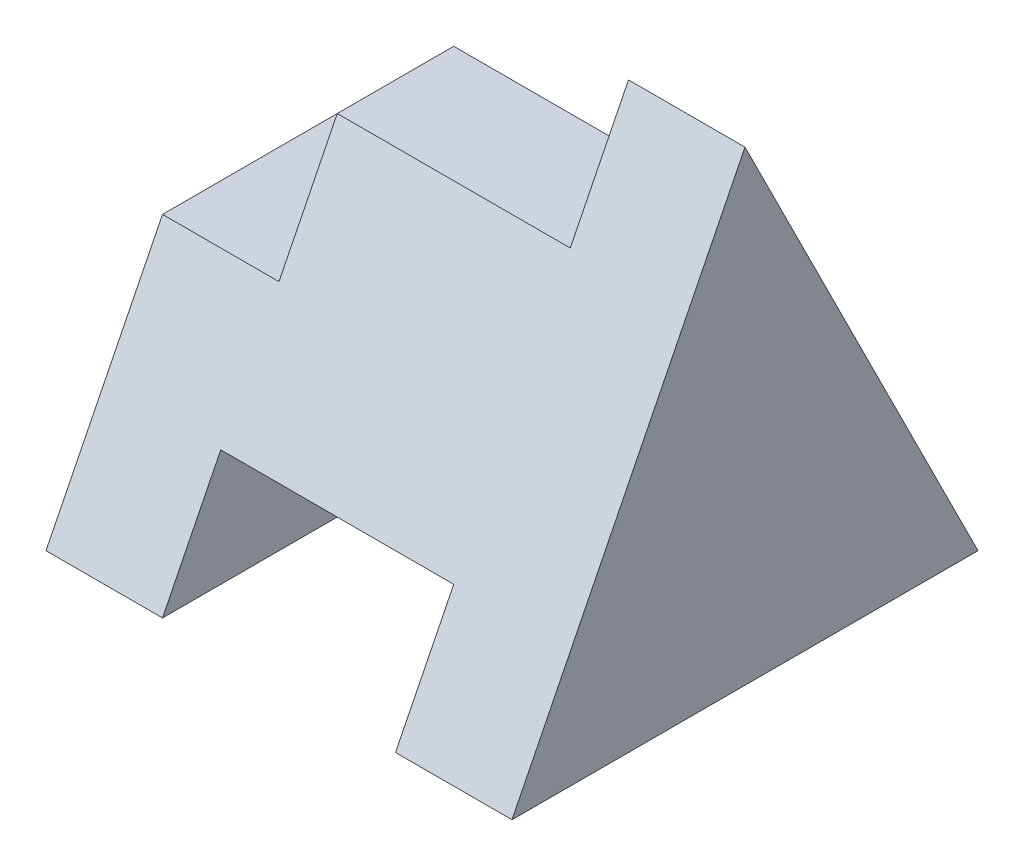
from build123d import *

# Parameters (mm, degrees)
BOSS_EXTRUDE1_DEPTH = 4
CUT_EXTRUDE2_DEPTH  = 10


with BuildPart() as part:
    # Sketch1 → Boss-Extrude1 (new body)
    with BuildSketch(Plane.XY):
        Polygon((0, 0), (0, 2), (1, 2), (1, 3), (3, 3), (3, 4), (4, 4), (4, 0), (3, 0), (3, 1), (1, 1), (1, 0), align=None)
    extrude(amount=BOSS_EXTRUDE1_DEPTH)

    # Sketch3 → Cut-Extrude2 (cut)
    with BuildSketch(Plane.ZY):
        Polygon((1, 2), (2, 4), (0, 4), (0, 2), align=None)
        Polygon((0, 0), (1, 2), (0, 2), align=None)
        Polygon((2, 4), (3, 2), (4, 2), (4, 4), align=None)
        Polygon((3, 2), (4, 0), (4, 2), align=None)
    extrude(amount=-CUT_EXTRUDE2_DEPTH, mode=Mode.SUBTRACT)


solid = part.part
